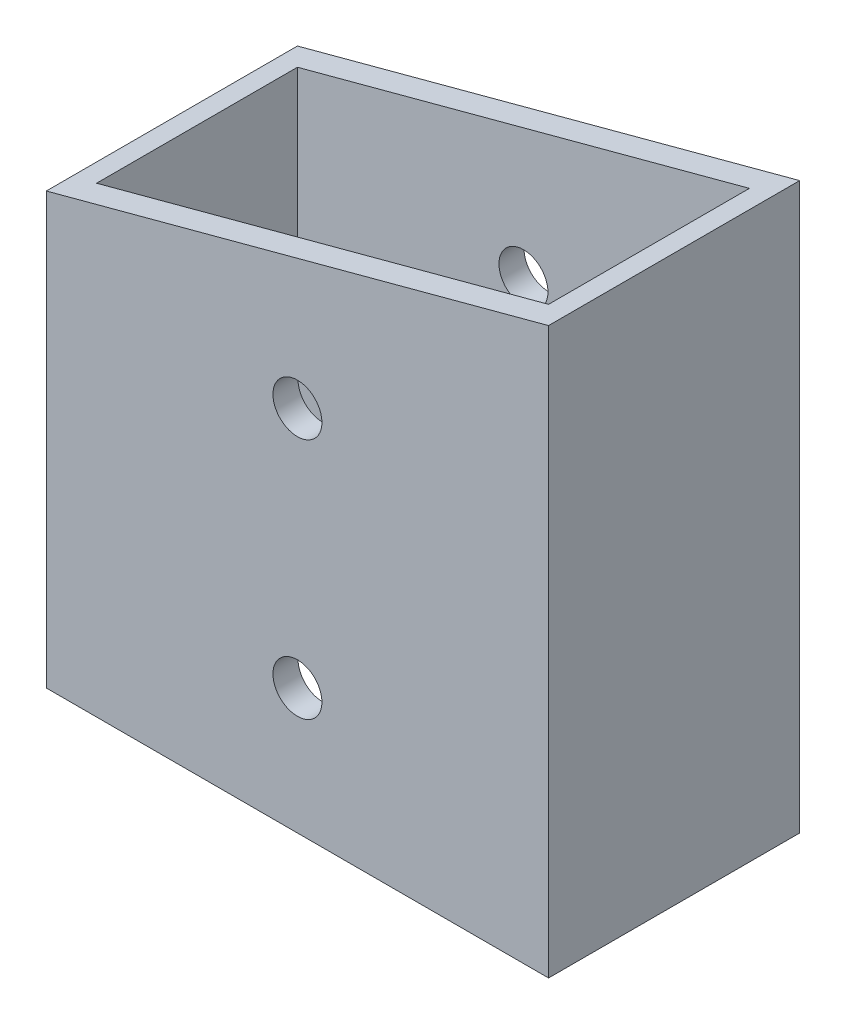
from build123d import *

# Parameters (mm, degrees)
SKETCH1_W           = 50.8
SKETCH1_H           = 25.4
SKETCH1_W_2         = 45.72
SKETCH1_H_2         = 20.32
EXTRUDE_THIN1_DEPTH = 53.975
CUT_EXTRUDE1_DEPTH  = 26.4
SKETCH3_W           = 50.8
SKETCH3_H           = 50.8
CUT_EXTRUDE2_DEPTH  = 26.4
SKETCH5_R           = 2.4765
CUT_EXTRUDE4_DEPTH  = 26.4


with BuildPart() as part:
    # Sketch1 → Extrude-Thin1 (new body, symmetric)
    with BuildSketch(Plane(origin=(0, 0, 0), x_dir=(1, 0, 0), z_dir=(0, 1, 0))):
        Rectangle(SKETCH1_W, SKETCH1_H)
        Rectangle(SKETCH1_W_2, SKETCH1_H_2, mode=Mode.SUBTRACT)
    extrude(amount=EXTRUDE_THIN1_DEPTH, both=True)

    # Sketch2 → Cut-Extrude1 (cut, through all)
    with BuildSketch(Plane.XY.offset(12.7)):
        Polygon((-25.4, 53.975), (25.4, 53.975), (-25.4, 40.363181024), align=None)
    extrude(amount=-CUT_EXTRUDE1_DEPTH, mode=Mode.SUBTRACT)

    # Sketch3 → Cut-Extrude2 (cut, through all)
    with BuildSketch(Plane.XY.offset(12.7)):
        with Locations((0, -28.575)):
            Rectangle(SKETCH3_W, SKETCH3_H)
    extrude(amount=-CUT_EXTRUDE2_DEPTH, mode=Mode.SUBTRACT)

    # Sketch5 → Cut-Extrude4 (cut, through all)
    with BuildSketch(Plane(origin=(0, 0, -12.7), x_dir=(-1, 0, 0), z_dir=(0, 0, -1))):
        with Locations((0, 9.525)):
            Circle(SKETCH5_R)
        with Locations((0, 34.021083021)):
            Circle(SKETCH5_R)
    extrude(amount=-CUT_EXTRUDE4_DEPTH, mode=Mode.SUBTRACT)


solid = part.part
